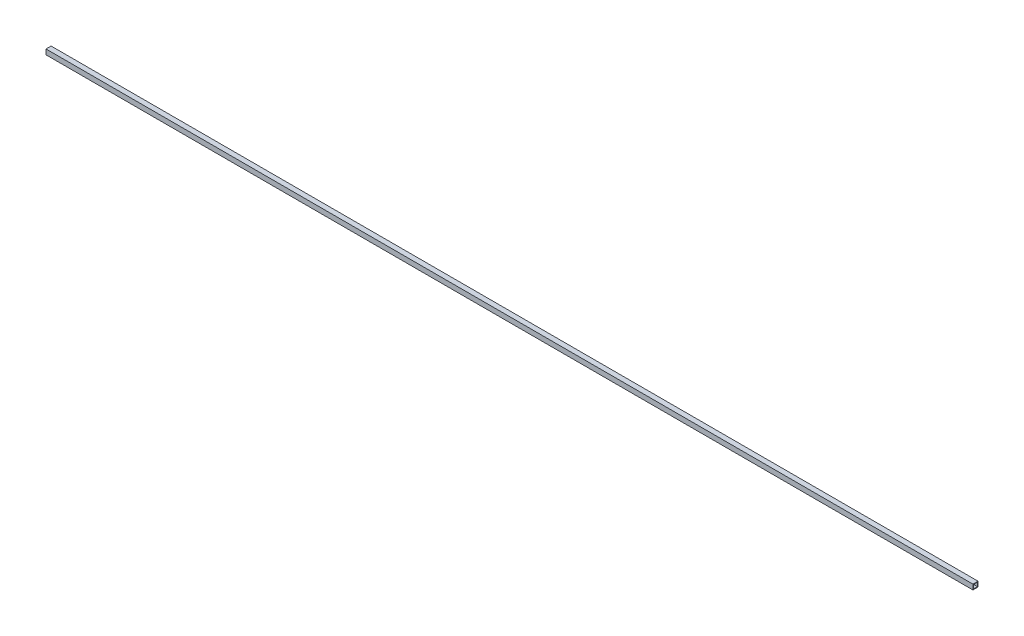
from build123d import *

# Parameters (mm, degrees)
SKETCH11_W                                     = 50.8
SKETCH11_H                                     = 50.8
SKETCH11_W_2                                   = 38.1
SKETCH11_H_2                                   = 38.1
AL_TUBE_SQUARE_AL_TUBE_2_SQR_X_0_25_WALL_DEPTH = 9244.33


with BuildPart() as part:
    # Sketch11 → Al tube square AL TUBE 2 SQR X 0.25 WALL(1) (new body)
    with BuildSketch(Plane.YZ):
        Rectangle(SKETCH11_W, SKETCH11_H)
        Rectangle(SKETCH11_W_2, SKETCH11_H_2, mode=Mode.SUBTRACT)
    extrude(amount=AL_TUBE_SQUARE_AL_TUBE_2_SQR_X_0_25_WALL_DEPTH)


solid = part.part
